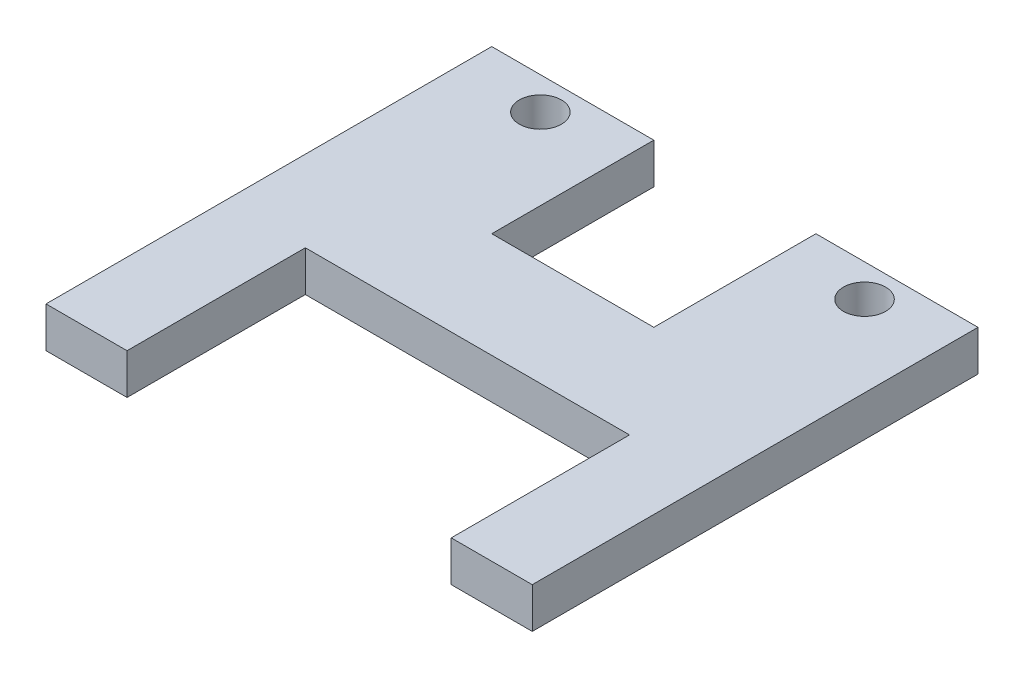
from build123d import *

# Parameters (mm, degrees)
SKETCH1_W           = 76.2
SKETCH1_H           = 69.85
BOSS_EXTRUDE1_DEPTH = 3.175
SKETCH2_W           = 50.8
SKETCH2_H           = 27.94
CUT_EXTRUDE1_DEPTH  = 7.35
SKETCH4_R           = 3.302
CUT_EXTRUDE2_DEPTH  = 7.35
SKETCH5_W           = 25.4
SKETCH5_H           = 25.4
CUT_EXTRUDE3_DEPTH  = 7.35


with BuildPart() as part:
    # Sketch1 → Boss-Extrude1 (new body, symmetric)
    with BuildSketch(Plane(origin=(0, 0, 0), x_dir=(1, 0, 0), z_dir=(0, 1, 0))):
        Rectangle(SKETCH1_W, SKETCH1_H)
    extrude(amount=BOSS_EXTRUDE1_DEPTH, both=True)

    # Sketch2 → Cut-Extrude1 (cut, through all)
    with BuildSketch(Plane(origin=(0, 3.175, 0), x_dir=(1, 0, 0), z_dir=(0, 1, 0))):
        with Locations((0, -20.955)):
            Rectangle(SKETCH2_W, SKETCH2_H)
    extrude(amount=-CUT_EXTRUDE1_DEPTH, mode=Mode.SUBTRACT)

    # Sketch4 → Cut-Extrude2 (cut, through all)
    with BuildSketch(Plane(origin=(0, 3.175, 0), x_dir=(1, 0, 0), z_dir=(0, 1, 0))):
        with Locations((-25.4, 29.845)):
            Circle(SKETCH4_R)
        with Locations((25.4, 29.845)):
            Circle(SKETCH4_R)
    extrude(amount=-CUT_EXTRUDE2_DEPTH, mode=Mode.SUBTRACT)

    # Sketch5 → Cut-Extrude3 (cut, through all)
    with BuildSketch(Plane(origin=(0, 3.175, 0), x_dir=(1, 0, 0), z_dir=(0, 1, 0))):
        with Locations((0, 22.225)):
            Rectangle(SKETCH5_W, SKETCH5_H)
    extrude(amount=-CUT_EXTRUDE3_DEPTH, mode=Mode.SUBTRACT)


solid = part.part
